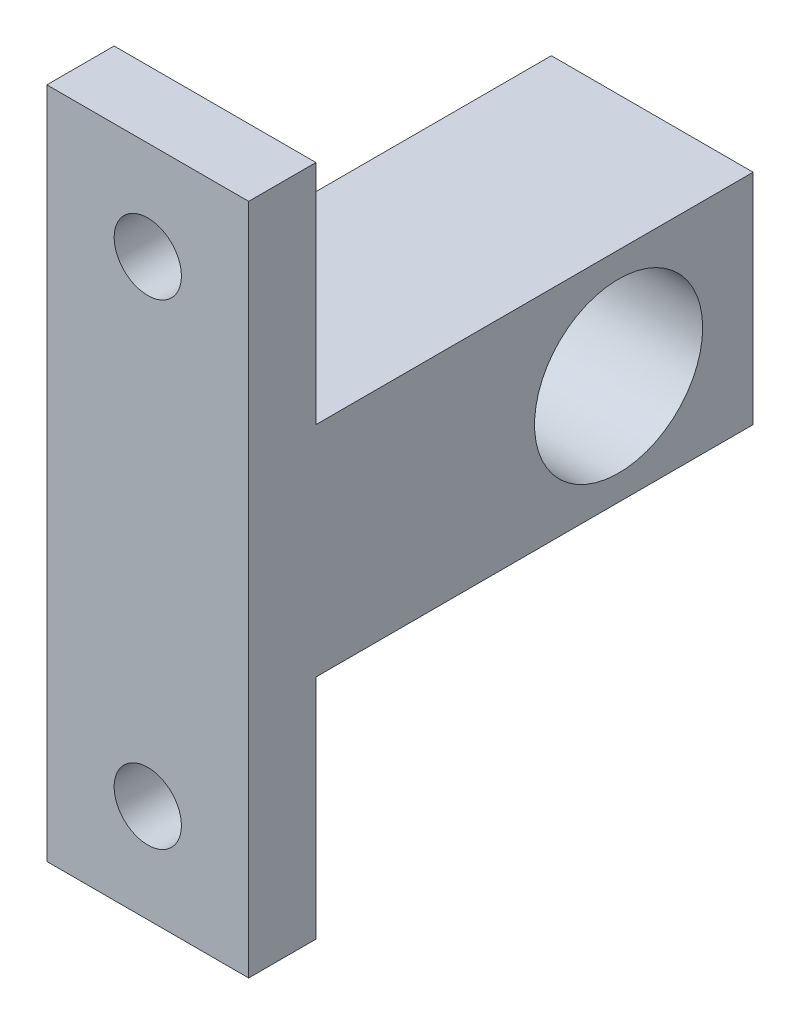
from build123d import *

# Parameters (mm, degrees)
SKETCH1_R           = 5
BOSS_EXTRUDE1_DEPTH = 6
SKETCH2_R           = 2
CUT_EXTRUDE1_DEPTH  = 5


with BuildPart() as part:
    # Sketch1 → Boss-Extrude1 (new body, symmetric)
    with BuildSketch(Plane(origin=(0, 0, 0), x_dir=(0, 0, -1), z_dir=(1, 0, 0))):
        Polygon((-22, -20), (-22, 20), (-18, 20), (-18, 6.5), (8, 6.5), (8, -6.5), (-18, -6.5), (-18, -20), align=None)
        Circle(SKETCH1_R, mode=Mode.SUBTRACT)
    extrude(amount=BOSS_EXTRUDE1_DEPTH, both=True)

    # Sketch2 → Cut-Extrude1 (cut, through all)
    with BuildSketch(Plane(origin=(0, 0, 18), x_dir=(-1, 0, 0), z_dir=(0, 0, -1))):
        with Locations((0, 14.149716829)):
            Circle(SKETCH2_R)
        with Locations((0, -14.149716829)):
            Circle(SKETCH2_R)
    extrude(amount=-CUT_EXTRUDE1_DEPTH, mode=Mode.SUBTRACT)


solid = part.part
